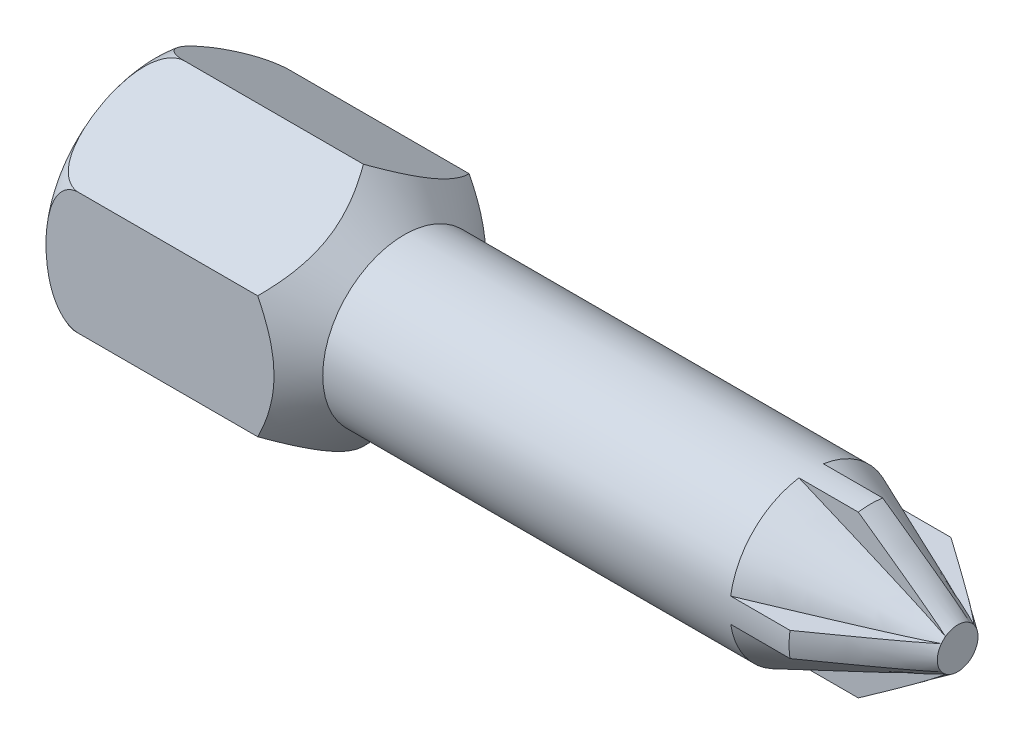
from build123d import *
from build123d.topology import SkipClean

# Parameters (mm, degrees)
SKETCH2_OUTSIDE_W   = 53.726
SKETCH2_OUTSIDE_H   = 53.726
CUT_EXTRUDE2_DEPTH  = 100
BOSS_EXTRUDE1_DEPTH = 18


with BuildPart() as part:
    # Sketch1 → Revolve1 (revolve)
    with BuildSketch(Plane(origin=(0, 0, 0), x_dir=(1, 0, 0), z_dir=(0, 0, -1)), mode=Mode.PRIVATE) as revolve1_sk:
        with BuildLine():
            Line((0, 0), (0, 10))
            ThreePointArc((0, 10), (1.464466094, 13.535533906), (5, 15))
            Line((5, 15), (27, 15))
            Line((27, 15), (32, 10))
            Line((32, 10), (82, 10))
            Line((82, 10), (100, 2.5))
            Line((100, 2.5), (100, 0))
            Line((100, 0), (0, 0))
        make_face()
    revolve(revolve1_sk.sketch.rotate(Axis((-28.136645963, 0, 0), (1, 0, 0)), 270), axis=Axis((-28.136645963, 0, 0), (1, 0, 0)))  # turned: the seam where the file's is

    # Sketch2 outside → Cut-Extrude2 (cut)
    with BuildSketch(Plane.ZY):
        Rectangle(SKETCH2_OUTSIDE_W, SKETCH2_OUTSIDE_H)
        Polygon((12.990381057, -7.5), (12.990381057, 7.5), (0, 15), (-12.990381057, 7.5), (-12.990381057, -7.5), (0, -15), align=None, mode=Mode.SUBTRACT)
    extrude(amount=-CUT_EXTRUDE2_DEPTH, mode=Mode.SUBTRACT)

    # Sketch5 → Boss-Extrude1 (add)
    with SkipClean():  # keep this step's faces unmerged: merging them makes the solid invalid here
        with BuildSketch(Plane(origin=(100, 0, 0), x_dir=(0, 0, -1), z_dir=(1, 0, 0))):
            with BuildLine():
                Line((-1.5, 2), (-1.5, 9.886859967))
                ThreePointArc((-1.5, 9.886859967), (0, 10), (1.5, 9.886859967))
                Line((1.5, 9.886859967), (1.5, 2))
                ThreePointArc((1.5, 2), (1.767766953, 1.767766953), (2, 1.5))
                Line((2, 1.5), (9.886859967, 1.5))
                ThreePointArc((9.886859967, 1.5), (10, 0), (9.886859967, -1.5))
                Line((9.886859967, -1.5), (2, -1.5))
                ThreePointArc((2, -1.5), (1.767766953, -1.767766953), (1.5, -2))
                Line((1.5, -2), (1.5, -9.886859967))
                ThreePointArc((1.5, -9.886859967), (0, -10), (-1.5, -9.886859967))
                Line((-1.5, -9.886859967), (-1.5, -2))
                ThreePointArc((-1.5, -2), (-1.767766953, -1.767766953), (-2, -1.5))
                Line((-2, -1.5), (-9.886859967, -1.5))
                ThreePointArc((-9.886859967, -1.5), (-10, 0), (-9.886859967, 1.5))
                Line((-9.886859967, 1.5), (-2, 1.5))
                ThreePointArc((-2, 1.5), (-1.767766953, 1.767766953), (-1.5, 2))
            make_face()
        extrude(amount=-BOSS_EXTRUDE1_DEPTH)

    # Sketch6 → Cut-Revolve1 (revolve, cut)
    with SkipClean():  # keep this step's faces unmerged: merging them makes the solid invalid here
        with BuildSketch(Plane.XY, mode=Mode.PRIVATE) as cut_revolve1_sk:
            Polygon((100, 2.5), (100, 10), (89.288889949, 10), align=None)
        revolve(cut_revolve1_sk.sketch.rotate(Axis((100, 0, 0), (1, 0, 0)), 90), axis=Axis((100, 0, 0), (1, 0, 0)), mode=Mode.SUBTRACT)  # turned: the seam where the file's is


solid = part.part
